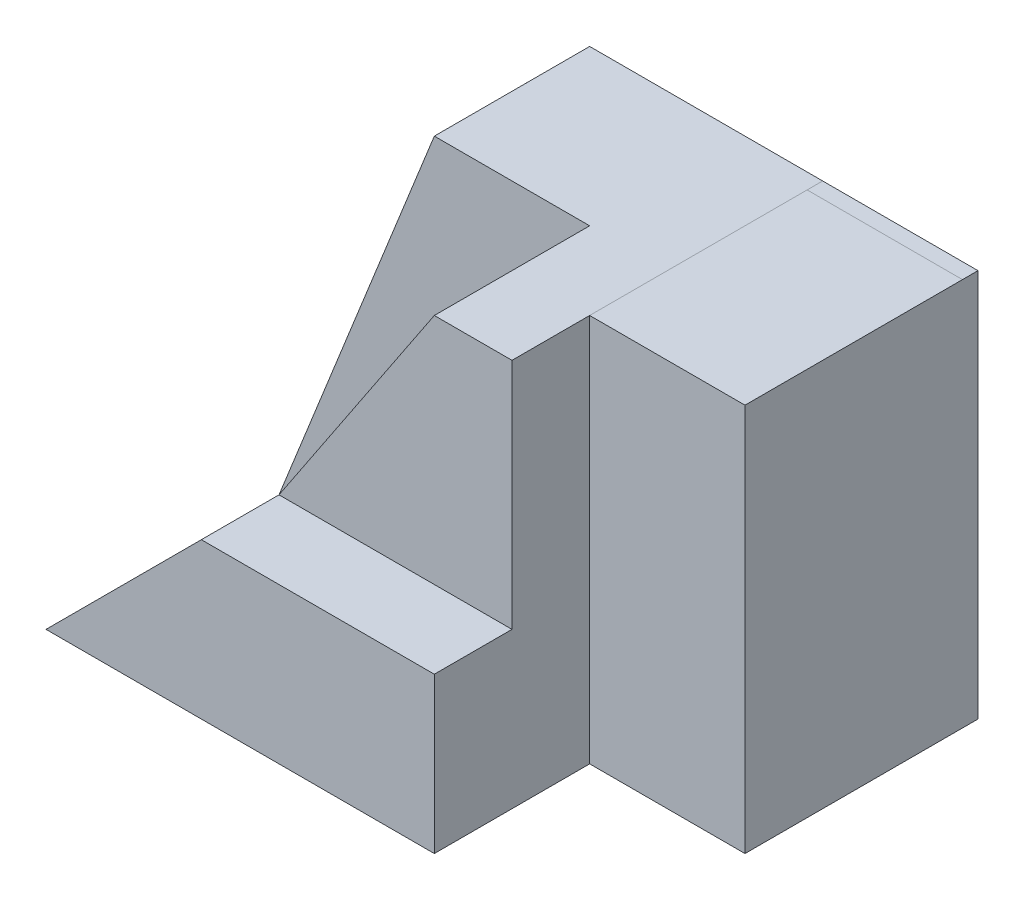
from build123d import *

# Parameters (mm, degrees)
SKETCH1_W            = 70
SKETCH1_H            = 50
BOSS_EXTRUDE1_DEPTH  = 50
CUT_EXTRUDE1_DEPTH   = 50
SKETCH3_W            = 10
SKETCH3_H            = 30
CUT_EXTRUDE2_DEPTH   = 121
SKETCH4_W            = 20
SKETCH4_H            = 20
CUT_EXTRUDE3_DEPTH   = 121
CUT_EXTRUDE8_DEPTH   = 30
CUT_EXTRUDE9_DEPTH   = 0.0001
SKETCH11_W           = 20
SKETCH11_H           = 2
BOSS_EXTRUDE8_DEPTH  = 0.0001
SKETCH12_W           = 20
SKETCH12_H           = 20
CUT_EXTRUDE10_DEPTH  = 0.0001
CUT_EXTRUDE11_DEPTH  = 0.001
CUT_EXTRUDE12_DEPTH  = 0.001
CUT_EXTRUDE13_DEPTH  = 9.001
BOSS_EXTRUDE14_DEPTH = 0.0002
SKETCH18_W           = 30
SKETCH18_H           = 28.284271247
CUT_EXTRUDE17_DEPTH  = 23.0002
CUT_EXTRUDE18_DEPTH  = 0.0001


with BuildPart() as part:
    # Sketch1 → Boss-Extrude1 (new body)
    with BuildSketch(Plane.XY):
        with Locations((35, 25)):
            Rectangle(SKETCH1_W, SKETCH1_H)
    extrude(amount=BOSS_EXTRUDE1_DEPTH)

    # Sketch2 → Cut-Extrude1 (cut)
    with BuildSketch(Plane.XY.offset(50)):
        Polygon((0, 0), (20, 50), (0, 50), align=None)
    extrude(amount=-CUT_EXTRUDE1_DEPTH, mode=Mode.SUBTRACT)

    # Sketch3 → Cut-Extrude2 (cut)
    with BuildSketch(Plane(origin=(70, 0, 0), x_dir=(0, 0, -1), z_dir=(1, 0, 0))):
        with Locations((-45, 35)):
            Rectangle(SKETCH3_W, SKETCH3_H)
    extrude(amount=-CUT_EXTRUDE2_DEPTH, mode=Mode.SUBTRACT)

    # Sketch4 → Cut-Extrude3 (cut)
    with BuildSketch(Plane.XZ):
        with Locations((60, 40)):
            Rectangle(SKETCH4_W, SKETCH4_H)
    extrude(amount=-CUT_EXTRUDE3_DEPTH, mode=Mode.SUBTRACT)

    # Sketch5 → Cut-Extrude8 (cut)
    with BuildSketch(Plane.XY.offset(50)):
        Polygon((0, 0), (20, 20), (40, 50), (20, 50), align=None)
    extrude(amount=-CUT_EXTRUDE8_DEPTH, mode=Mode.SUBTRACT)

    # Sketch10 → Cut-Extrude9 (cut)
    with BuildSketch(Plane(origin=(0, 50, 0), x_dir=(1, 0, 0), z_dir=(0, 1, 0))):
        Polygon((20, 0), (50, 0), (50, -40), (40, -40), (40, -10), (20, -10), align=None)
    extrude(amount=-CUT_EXTRUDE9_DEPTH, mode=Mode.SUBTRACT)

    # Sketch11 → Boss-Extrude8 (add)
    with BuildSketch(Plane(origin=(0, 50, 0), x_dir=(1, 0, 0), z_dir=(0, 1, 0))):
        with Locations((60, -1)):
            Rectangle(SKETCH11_W, SKETCH11_H)
    extrude(amount=BOSS_EXTRUDE8_DEPTH)

    # Sketch12 → Cut-Extrude10 (cut)
    with BuildSketch(Plane(origin=(0, 50, 0), x_dir=(1, 0, 0), z_dir=(0, 1, 0))):
        with Locations((30, -20)):
            Rectangle(SKETCH12_W, SKETCH12_H)
    extrude(amount=-CUT_EXTRUDE10_DEPTH, mode=Mode.SUBTRACT)

    # Sketch14 → Cut-Extrude11 (cut)
    with BuildSketch(Plane(origin=(0, 0, 0), x_dir=(0, 0, 1), z_dir=(-0.707106781, 0.707106781, 0))):
        Polygon((20, 28.284271247), (50, 28.284271247), (50, 0), (30, 0), align=None)
    extrude(amount=-CUT_EXTRUDE11_DEPTH, mode=Mode.SUBTRACT)

    # Sketch15 → Cut-Extrude12 (cut)
    with BuildSketch(Plane(origin=(0, 0, 0), x_dir=(0, 0, 1), z_dir=(-0.928476691, 0.371390676, 0))):
        Polygon((0, 53.851648071), (30, 0), (0, 0), align=None)
    extrude(amount=-CUT_EXTRUDE12_DEPTH, mode=Mode.SUBTRACT)

    # Sketch16 → Cut-Extrude13 (cut)
    with BuildSketch(Plane(origin=(0.000928477, -0.000371391, 0), x_dir=(0, 0, 1), z_dir=(-0.928476691, 0.371390676, 0))):
        Polygon((20, 17.950549357), (29.998700133, 0.002333333), (20, 0.002333333), align=None)
    extrude(amount=-CUT_EXTRUDE13_DEPTH, mode=Mode.SUBTRACT)

    # Sketch17 → Boss-Extrude14 (add)
    with BuildSketch(Plane(origin=(0, 0, 0), x_dir=(0, 0, 1), z_dir=(-0.707106781, 0.707106781, 0))):
        Polygon((20, 28.284271247), (20, 19.529615861), (30, 0), align=None)
    extrude(amount=BOSS_EXTRUDE14_DEPTH)

    # Sketch18 → Cut-Extrude17 (cut)
    with BuildSketch(Plane(origin=(0.000707107, -0.000707107, 0), x_dir=(0, 0, 1), z_dir=(-0.707106781, 0.707106781, 0))):
        with Locations((35, 14.142135624)):
            Rectangle(SKETCH18_W, SKETCH18_H)
    extrude(amount=CUT_EXTRUDE17_DEPTH, mode=Mode.SUBTRACT)

    # Sketch19 → Cut-Extrude18 (cut)
    with BuildSketch(Plane(origin=(0, 0, 0), x_dir=(0, 0, 1), z_dir=(-0.928476691, 0.371390676, 0))):
        Polygon((17.214569927, 22.950549357), (20, 22.950549357), (20, 17.950549357), align=None)
    extrude(amount=-CUT_EXTRUDE18_DEPTH, mode=Mode.SUBTRACT)


solid = part.part
